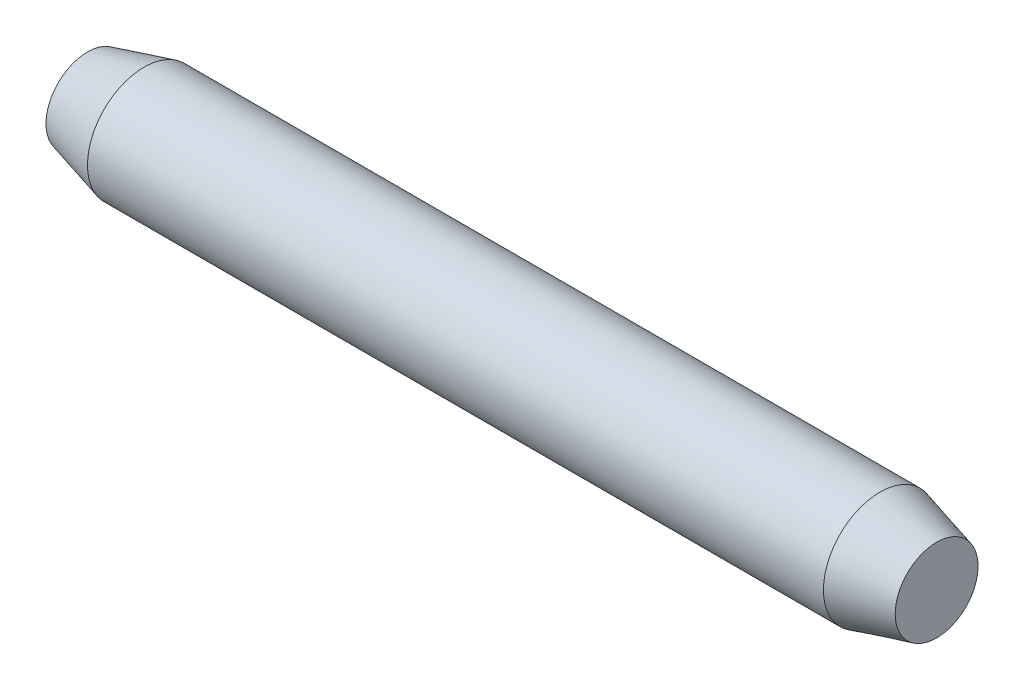
from build123d import *


with BuildPart() as part:
    # Sketch1 → Base-Revolve (revolve)
    with BuildSketch(Plane.XY, mode=Mode.PRIVATE) as base_revolve_sk:
        Polygon((0, 0), (15, 0), (15, 0.732050808), (14, 1), (1, 1), (0, 0.732050808), align=None)
    revolve(base_revolve_sk.sketch.rotate(Axis((-6.35, 0, 0), (1, 0, 0)), 90), axis=Axis((-6.35, 0, 0), (1, 0, 0)))  # turned: the seam where the file's is


solid = part.part
